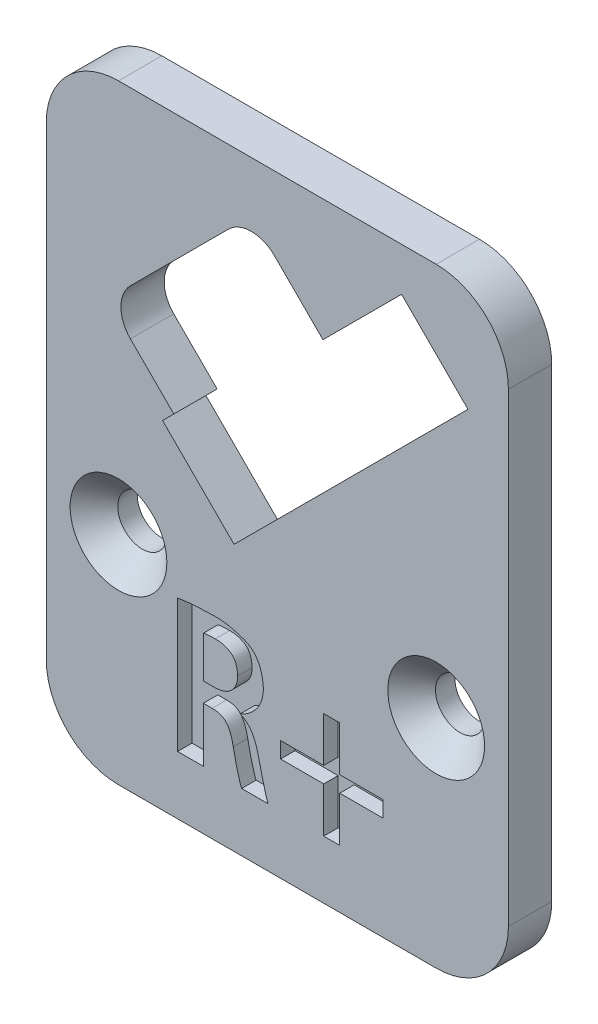
from build123d import *

# Parameters (mm, degrees)
SKETCH2_W                                           = 31.995270606
SKETCH2_H                                           = 42.204432033
BOSS_EXTRUDE2_DEPTH                                 = 3
FILLET1_R                                           = 5
CUT_EXTRUDE1_DEPTH                                  = 1
CSK_FOR_M3_COUNTERSUNK_FLAT_HEAD_SCREW1_D           = 3.4
CSK_FOR_M3_COUNTERSUNK_FLAT_HEAD_SCREW1_DEPTH       = 20
CSK_FOR_M3_COUNTERSUNK_FLAT_HEAD_SCREW1_CSINK_D     = 6.7
CSK_FOR_M3_COUNTERSUNK_FLAT_HEAD_SCREW1_CSINK_ANGLE = 90
CSK_FOR_M3_COUNTERSUNK_FLAT_HEAD_SCREW1_TIP         = 1.021463052


with BuildPart() as part:
    # Sketch2 → Boss-Extrude2 (new body)
    with BuildSketch(Plane.XY):
        with Locations((-46.502364697, -1.397783984)):
            Rectangle(SKETCH2_W, SKETCH2_H)
        with BuildLine():
            Line((-43.345645687, 11.259709818), (-37.900923472, 16.704432033))
            Line((-37.900923472, 16.704432033), (-33.304729394, 12.108237955))
            Line((-33.304729394, 12.108237955), (-40.481863223, 4.931104126))
            Line((-40.481863223, 4.931104126), (-47.694352391, -2.281385042))
            Line((-47.694352391, -2.281385042), (-49.497474683, -4.084507334))
            Line((-49.497474683, -4.084507334), (-54.270445456, 0.688463439))
            Line((-54.270445456, 0.688463439), (-54.447222151, 0.865240134))
            Line((-54.447222151, 0.865240134), (-53.669404692, 1.643057594))
            Line((-53.669404692, 1.643057594), (-56.674608512, 4.648261414))
            ThreePointArc((-56.674608512, 4.648261414), (-57.333618254, 6.239251671), (-56.674608512, 7.830241929))
            Line((-56.674608512, 7.830241929), (-49.886383413, 14.618467028))
            ThreePointArc((-49.886383413, 14.618467028), (-48.295393155, 15.277476771), (-46.704402897, 14.618467028))
            Line((-46.704402897, 14.618467028), (-43.345645687, 11.259709818))
        make_face(mode=Mode.SUBTRACT)
    extrude(amount=BOSS_EXTRUDE2_DEPTH)

    # Fillet1
    fillet1_edges = [part.edges().sort_by_distance(p)[0] for p in [
        (-62.5, 19.704432033, 1.5),
        (-30.504729394, 19.704432033, 1.5),
        (-30.504729394, -22.5, 1.5),
        (-62.5, -22.5, 1.5),
    ]]
    fillet(fillet1_edges, radius=FILLET1_R)

    # Sketch3 → Cut-Extrude1 (cut)
    with BuildSketch(Plane.XY.offset(3)):
        with BuildLine():
            Line((-53.406595938, -18.458875061), (-51.622591884, -18.458875061))
            Line((-51.622591884, -18.458875061), (-51.622591884, -14.672122679))
            Line((-51.622591884, -14.672122679), (-51.017108914, -14.672122679))
            add(Edge.make_bspline(
                [(-51.017108914, -14.672122679), (-50.967221063, -14.6725211), (-50.869089583, -14.673304811), (-50.726307211, -14.687536776), (-50.59134918, -14.711269605), (-50.466393214, -14.74890661), (-50.349448029, -14.795186794), (-50.243372763, -14.856795477), (-50.144072949, -14.926037335), (-50.054957683, -15.010644116), (-49.973820519, -15.109304476), (-49.895499782, -15.22163632), (-49.82653007, -15.353586411), (-49.759217057, -15.500135947), (-49.701088017, -15.664809001), (-49.643553431, -15.843956856), (-49.595679106, -16.041536599), (-49.567178312, -16.179191645), (-49.552376571, -16.25068209)],
                knots=[0, 0, 0, 0, 0.000149599, 0.000294267, 0.000429961, 0.000559969, 0.000685182, 0.000806276, 0.000927115, 0.001047609, 0.001173509, 0.001309883, 0.001457588, 0.001619475, 0.001793345, 0.001981055, 0.002183769, 0.002402801, 0.002402801, 0.002402801, 0.002402801], degree=3))
            add(Edge.make_bspline(
                [(-49.552376571, -16.25068209), (-49.525198055, -16.387123246), (-49.473103018, -16.648649934), (-49.392970197, -17.023584407), (-49.311565779, -17.362673147), (-49.236540071, -17.666100231), (-49.159754201, -17.927379781), (-49.09515802, -18.146751884), (-49.035019782, -18.32008565), (-48.991587507, -18.417682148), (-48.972926992, -18.45961412)],
                knots=[0, 0, 0, 0, 0.000417367, 0.000799998, 0.001150089, 0.001463532, 0.001737527, 0.001966934, 0.002149658, 0.002287303, 0.002287303, 0.002287303, 0.002287303], degree=3))
            Line((-48.972926992, -18.45961412), (-47.136904169, -18.458875061))
            add(Edge.make_bspline(
                [(-47.136904169, -18.458875061), (-47.161564895, -18.402686862), (-47.218007052, -18.274086301), (-47.289802608, -18.048232695), (-47.371028766, -17.770288113), (-47.454128887, -17.444111213), (-47.54108784, -17.08294144), (-47.635197109, -16.699954349), (-47.729326366, -16.299301278), (-47.793532678, -16.026508782), (-47.826319189, -15.887209172)],
                knots=[0, 0, 0, 0, 0.000183977, 0.000421076, 0.000710029, 0.001052867, 0.00143062, 0.001824558, 0.002235981, 0.002665299, 0.002665299, 0.002665299, 0.002665299], degree=3))
            add(Edge.make_bspline(
                [(-47.826319189, -15.887209172), (-47.853811517, -15.773168942), (-47.906950904, -15.5527428), (-48.012466172, -15.242137194), (-48.133574292, -14.961961493), (-48.271280255, -14.712628496), (-48.430628441, -14.494327391), (-48.613783885, -14.309294243), (-48.824443435, -14.160659908), (-48.979271119, -14.089741414), (-49.057210567, -14.054041414)],
                knots=[0, 0, 0, 0, 0.000351778, 0.000679945, 0.00098268, 0.001266475, 0.001532679, 0.001790935, 0.002044255, 0.002301038, 0.002301038, 0.002301038, 0.002301038], degree=3))
            Line((-49.057210567, -14.054041414), (-49.055826761, -14.017001018))
            add(Edge.make_bspline(
                [(-49.055826761, -14.017001018), (-48.947444474, -13.970005767), (-48.731176328, -13.876230519), (-48.437027307, -13.676157256), (-48.16698609, -13.438863882), (-47.96738166, -13.208200023), (-47.827527505, -13.003332314), (-47.734510158, -12.840203194), (-47.654705939, -12.668874791), (-47.590237223, -12.488727388), (-47.536975559, -12.300576236), (-47.49880838, -12.103222096), (-47.473716885, -11.89781805), (-47.468833592, -11.757970901), (-47.466358087, -11.68707768)],
                knots=[0, 0, 0, 0, 0.000353722, 0.000705825, 0.001061629, 0.00143016, 0.001617179, 0.001805135, 0.001992894, 0.002183416, 0.002378543, 0.002578963, 0.00278587, 0.002998596, 0.002998596, 0.002998596, 0.002998596], degree=3))
            add(Edge.make_bspline(
                [(-47.466358087, -11.68707768), (-47.471335477, -11.614412673), (-47.481116943, -11.471612893), (-47.510316581, -11.263842973), (-47.54492077, -11.065622921), (-47.588249594, -10.87842638), (-47.641427562, -10.701449), (-47.702511342, -10.534699828), (-47.772245942, -10.378252437), (-47.852158355, -10.232984263), (-47.939986965, -10.098344998), (-48.033967332, -9.971834439), (-48.141219561, -9.860313263), (-48.25318803, -9.754798011), (-48.376606652, -9.662838486), (-48.507424148, -9.578828028), (-48.647802909, -9.507518301), (-48.843870315, -9.427166253), (-49.092633379, -9.344888092), (-49.385532702, -9.252977107), (-49.674059157, -9.184061361), (-49.953635545, -9.126227189), (-50.227113002, -9.088865813), (-50.492941892, -9.061958609), (-50.752364485, -9.057551627), (-50.922597141, -9.065240143), (-51.006268241, -9.069019128)],
                knots=[0, 0, 0, 0, 0.000218439, 0.000429273, 0.000629045, 0.000821988, 0.00100531, 0.001183082, 0.001354416, 0.001518656, 0.001679866, 0.001836496, 0.001990536, 0.002143381, 0.002297551, 0.002451481, 0.002609328, 0.002769115, 0.003086745, 0.003395031, 0.003689736, 0.003976245, 0.004251139, 0.004517418, 0.004777346, 0.005028594, 0.005028594, 0.005028594, 0.005028594], degree=3))
            add(Edge.make_bspline(
                [(-51.006268241, -9.069019128), (-51.229920663, -9.07164849), (-51.667065111, -9.076787763), (-52.203799431, -9.112050461), (-52.610847653, -9.150113546), (-52.893038741, -9.181499683), (-53.157150271, -9.216172913), (-53.326467573, -9.243625216), (-53.408350131, -9.256901264)],
                knots=[0, 0, 0, 0, 0.000670904, 0.001311329, 0.001612901, 0.001897363, 0.00216308, 0.002411924, 0.002411924, 0.002411924, 0.002411924], degree=3))
            Line((-53.408350131, -9.256901264), (-53.406595938, -18.458875061))
        make_face()
        with BuildLine():
            add(Edge.make_bspline(
                [(-51.622591884, -10.475098321), (-51.578289384, -10.463741178), (-51.474495266, -10.437133094), (-51.291682029, -10.418528414), (-51.062136724, -10.403821129), (-50.893349772, -10.40361956), (-50.800827027, -10.403509067)],
                knots=[0, 0, 0, 0, 0.000137048, 0.000321084, 0.000549784, 0.00082724, 0.00082724, 0.00082724, 0.00082724], degree=3))
            add(Edge.make_bspline(
                [(-50.800827027, -10.403509067), (-50.713411846, -10.402981113), (-50.538343762, -10.40192377), (-50.277794239, -10.452443011), (-50.02227135, -10.54015698), (-49.815350935, -10.642172207), (-49.660308674, -10.749873331), (-49.556880046, -10.851803167), (-49.46929571, -10.972739958), (-49.393832963, -11.111515899), (-49.338533994, -11.270485036), (-49.291412353, -11.445599811), (-49.26254282, -11.640002112), (-49.25453627, -11.775957367), (-49.250360427, -11.846865291)],
                knots=[0, 0, 0, 0, 0.000261725, 0.000524161, 0.000791249, 0.001070808, 0.00121308, 0.001355871, 0.001504077, 0.001659631, 0.001827951, 0.00200768, 0.002203123, 0.002416175, 0.002416175, 0.002416175, 0.002416175], degree=3))
            add(Edge.make_bspline(
                [(-49.250360427, -11.846865291), (-49.252345828, -11.901954186), (-49.256225356, -12.009599393), (-49.277748827, -12.166460507), (-49.310814955, -12.315396112), (-49.357636445, -12.455901219), (-49.420346886, -12.587424294), (-49.495248035, -12.710240218), (-49.584778187, -12.823418468), (-49.684256839, -12.929228854), (-49.796941896, -13.023790308), (-49.920064233, -13.107175482), (-50.055738699, -13.175598565), (-50.200855706, -13.233265514), (-50.357133256, -13.279426838), (-50.523528709, -13.311908188), (-50.700774743, -13.333661231), (-50.822416839, -13.337439587), (-50.885110602, -13.339386933)],
                knots=[0, 0, 0, 0, 0.000165289, 0.000322979, 0.000474201, 0.000622458, 0.000766196, 0.000910448, 0.001053055, 0.001198372, 0.001345408, 0.001493457, 0.001643451, 0.001800288, 0.001961411, 0.002131526, 0.002308376, 0.002496463, 0.002496463, 0.002496463, 0.002496463], degree=3))
            Line((-50.885110602, -13.339386933), (-51.622591884, -13.33763274))
            Line((-51.622591884, -13.33763274), (-51.622591884, -10.475098321))
        make_face(mode=Mode.SUBTRACT)
        Polygon((-46.278275536, -14.236655826), (-46.278275536, -15.34639128), (-43.292566927, -15.34639128), (-43.292566927, -18.477744211), (-42.182831473, -18.477744211), (-42.182831473, -15.34639128), (-39.197122864, -15.34639128), (-39.197122864, -14.236655826), (-42.182831473, -14.236655826), (-42.182831473, -11.129576949), (-43.292566927, -11.129576949), (-43.292566927, -14.236655826), align=None)
    extrude(amount=-CUT_EXTRUDE1_DEPTH, mode=Mode.SUBTRACT)

    # CSK for M3 Countersunk Flat Head Screw1
    with Locations(Plane(origin=(-57.5, -7.5, 3), x_dir=(1, 0, 0), z_dir=(0, 0, 1))):
        with Locations((0, 0), (21.995270606, 0)):
            CounterSinkHole(CSK_FOR_M3_COUNTERSUNK_FLAT_HEAD_SCREW1_D / 2, CSK_FOR_M3_COUNTERSUNK_FLAT_HEAD_SCREW1_CSINK_D / 2, depth=CSK_FOR_M3_COUNTERSUNK_FLAT_HEAD_SCREW1_DEPTH, counter_sink_angle=CSK_FOR_M3_COUNTERSUNK_FLAT_HEAD_SCREW1_CSINK_ANGLE)
            with Locations((0, 0, -(CSK_FOR_M3_COUNTERSUNK_FLAT_HEAD_SCREW1_DEPTH + CSK_FOR_M3_COUNTERSUNK_FLAT_HEAD_SCREW1_TIP / 2))):  # 118° drill point
                Cone(0, CSK_FOR_M3_COUNTERSUNK_FLAT_HEAD_SCREW1_D / 2, CSK_FOR_M3_COUNTERSUNK_FLAT_HEAD_SCREW1_TIP, mode=Mode.SUBTRACT)


solid = part.part
